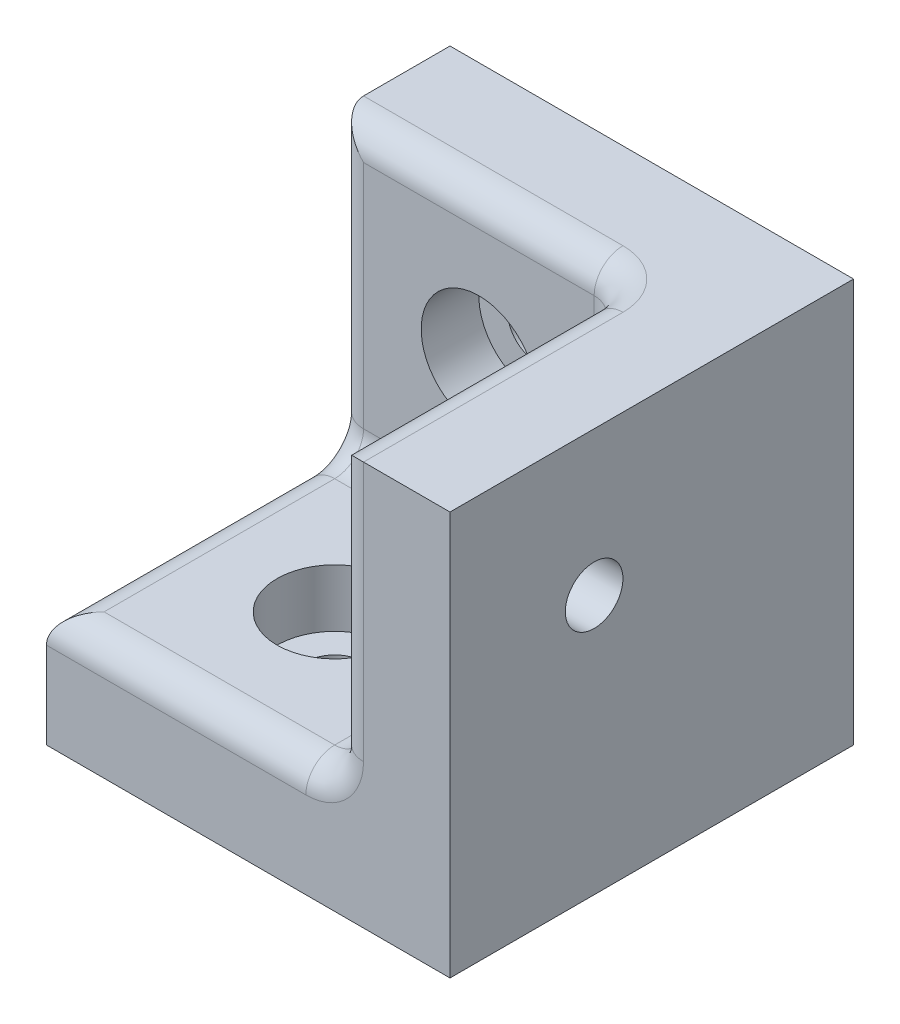
from build123d import *

# Parameters (mm, degrees)
ESQUISSE1_W             = 10
ESQUISSE1_H             = 14
BOSS_EXTRU_1_DEPTH      = 4
ESQUISSE2_W             = 10
ESQUISSE2_H             = 4
BOSS_EXTRU_2_DEPTH      = 10
ESQUISSE3_R             = 1
ENL_V_MAT_EXTRU_1_DEPTH = 5
ESQUISSE4_R             = 1
ENL_V_MAT_EXTRU_2_DEPTH = 5
ESQUISSE5_R             = 2
ENL_V_MAT_EXTRU_3_DEPTH = 2
ESQUISSE6_R             = 2
ENL_V_MAT_EXTRU_4_DEPTH = 2
ESQUISSE7_W             = 14
ESQUISSE7_H             = 14
BOSS_EXTRU_3_DEPTH      = 4
ESQUISSE8_R             = 1
ENL_V_MAT_EXTRU_5_DEPTH = 5
ESQUISSE9_R             = 2
ENL_V_MAT_EXTRU_6_DEPTH = 2
CONG_1_R                = 1


with BuildPart() as part:
    # Esquisse1 → Boss.-Extru.1 (new body)
    with BuildSketch(Plane.XY):
        with Locations((0, 7)):
            Rectangle(ESQUISSE1_W, ESQUISSE1_H)
    extrude(amount=BOSS_EXTRU_1_DEPTH)

    # Esquisse2 → Boss.-Extru.2 (add)
    with BuildSketch(Plane.XY.offset(4)):
        with Locations((0, 2)):
            Rectangle(ESQUISSE2_W, ESQUISSE2_H)
    extrude(amount=BOSS_EXTRU_2_DEPTH)

    # Esquisse3 → Enlèv. mat.-Extru.1 (cut, through all)
    with BuildSketch(Plane.XY.offset(4)):
        with Locations((0, 9)):
            Circle(ESQUISSE3_R)
    extrude(amount=-ENL_V_MAT_EXTRU_1_DEPTH, mode=Mode.SUBTRACT)

    # Esquisse4 → Enlèv. mat.-Extru.2 (cut, through all)
    with BuildSketch(Plane(origin=(0, 4, 0), x_dir=(1, 0, 0), z_dir=(0, 1, 0))):
        with Locations(Location((0, -9, 0), (0, 0, 270))):  # turned: the seam where the file's is
            Circle(ESQUISSE4_R)
    extrude(amount=-ENL_V_MAT_EXTRU_2_DEPTH, mode=Mode.SUBTRACT)

    # Esquisse5 → Enlèv. mat.-Extru.3 (cut)
    with BuildSketch(Plane.XY.offset(4)):
        with Locations((0, 9)):
            Circle(ESQUISSE5_R)
    extrude(amount=-ENL_V_MAT_EXTRU_3_DEPTH, mode=Mode.SUBTRACT)

    # Esquisse6 → Enlèv. mat.-Extru.4 (cut)
    with BuildSketch(Plane(origin=(0, 4, 0), x_dir=(1, 0, 0), z_dir=(0, 1, 0))):
        with Locations(Location((0, -9, 0), (0, 0, 270))):  # turned: the seam where the file's is
            Circle(ESQUISSE6_R)
    extrude(amount=-ENL_V_MAT_EXTRU_4_DEPTH, mode=Mode.SUBTRACT)

    # Esquisse7 → Boss.-Extru.3 (add)
    with BuildSketch(Plane(origin=(5, 0, 0), x_dir=(0, 0, -1), z_dir=(1, 0, 0))):
        with Locations((-7, 7)):
            Rectangle(ESQUISSE7_W, ESQUISSE7_H)
    extrude(amount=BOSS_EXTRU_3_DEPTH)

    # Esquisse8 → Enlèv. mat.-Extru.5 (cut, through all)
    with BuildSketch(Plane.ZY.offset(-5)):
        with Locations((9, 9)):
            Circle(ESQUISSE8_R)
    extrude(amount=-ENL_V_MAT_EXTRU_5_DEPTH, mode=Mode.SUBTRACT)

    # Esquisse9 → Enlèv. mat.-Extru.6 (cut)
    with BuildSketch(Plane.ZY.offset(-5)):
        with Locations((9, 9)):
            Circle(ESQUISSE9_R)
    extrude(amount=-ENL_V_MAT_EXTRU_6_DEPTH, mode=Mode.SUBTRACT)

    # Congé1
    cong_1_edges = [part.edges().sort_by_distance(p)[0] for p in [
        (5, 9, 4),
        (-5, 4, 9),
        (0, 4, 4),
        (5, 4, 9),
        (0, 14, 4),
        (0, 4, 14),
        (-5, 9, 4),
        (5, 14, 9),
        (5, 9, 14),
    ]]
    fillet(cong_1_edges, radius=CONG_1_R)


solid = part.part
